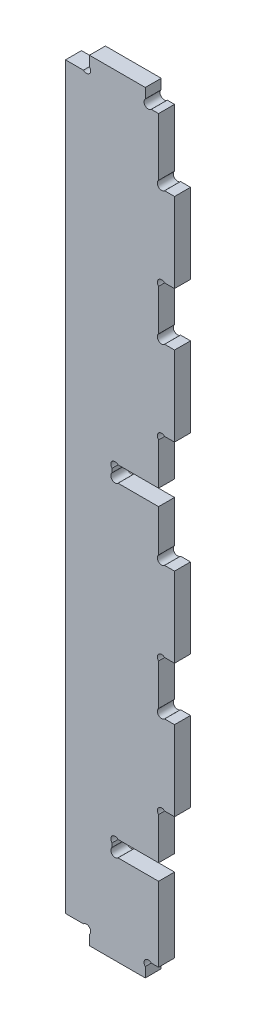
from build123d import *

# Parameters (mm, degrees)
EXTRUSION1_DEPTH        = 6
ESQUISSE2_R             = 1.1
ENL_V_MAT_EXTRU_1_DEPTH = 2


with BuildPart() as part:
    # Esquisse1 → Extrusion1 (new body)
    with BuildSketch(Plane.XY):
        with BuildLine():
            Line((0, 6), (6.7372583, 6))
            ThreePointArc((6.7372583, 6), (9, 6), (9, 3.7372583))
            Line((9, 3.7372583), (9, 0))
            Line((9, 0), (30, 0))
            Line((30, 0), (30, 3.7372583))
            ThreePointArc((30, 3.7372583), (30, 6), (32.2627417, 6))
            Line((32.2627417, 6), (35, 6))
            Line((35, 6), (35, 34))
            Line((35, 34), (19.7627417, 34))
            ThreePointArc((19.7627417, 34), (17.5, 34), (17.5, 36.2627417))
            Line((17.5, 36.2627417), (17.5, 37.7372583))
            ThreePointArc((17.5, 37.7372583), (17.5, 40), (19.7627417, 40))
            Line((19.7627417, 40), (35, 40))
            Line((35, 40), (35, 55.7372583))
            ThreePointArc((35, 55.7372583), (35, 58), (37.2627417, 58))
            Line((37.2627417, 58), (41, 58))
            Line((41, 58), (41, 88))
            Line((41, 88), (37.2627417, 88))
            ThreePointArc((37.2627417, 88), (35, 88), (35, 90.2627417))
            Line((35, 90.2627417), (35, 105.7372583))
            ThreePointArc((35, 105.7372583), (35, 108), (37.2627417, 108))
            Line((37.2627417, 108), (41, 108))
            Line((41, 108), (41, 138))
            Line((41, 138), (37.2627417, 138))
            ThreePointArc((37.2627417, 138), (35, 138), (35, 140.2627417))
            Line((35, 140.2627417), (35, 156))
            Line((35, 156), (19.7627417, 156))
            ThreePointArc((19.7627417, 156), (17.5, 156), (17.5, 158.2627417))
            Line((17.5, 158.2627417), (17.5, 159.7372583))
            ThreePointArc((17.5, 159.7372583), (17.5, 162), (19.7627417, 162))
            Line((19.7627417, 162), (35, 162))
            Line((35, 162), (35, 177.7372583))
            ThreePointArc((35, 177.7372583), (35, 180), (37.2627417, 180))
            Line((37.2627417, 180), (41, 180))
            Line((41, 180), (41, 210))
            Line((41, 210), (37.2627417, 210))
            ThreePointArc((37.2627417, 210), (35, 210), (35, 212.2627417))
            Line((35, 212.2627417), (35, 227.7372583))
            ThreePointArc((35, 227.7372583), (35, 230), (37.2627417, 230))
            Line((37.2627417, 230), (41, 230))
            Line((41, 230), (41, 260))
            Line((41, 260), (37.2627417, 260))
            ThreePointArc((37.2627417, 260), (35, 260), (35, 262.2627417))
            Line((35, 262.2627417), (35, 284))
            Line((35, 284), (32.2627417, 284))
            ThreePointArc((32.2627417, 284), (30, 284), (30, 286.2627417))
            Line((30, 286.2627417), (30, 290))
            Line((30, 290), (9, 290))
            Line((9, 290), (9, 286.2627417))
            ThreePointArc((9, 286.2627417), (9, 284), (6.7372583, 284))
            Line((6.7372583, 284), (0, 284))
            Line((0, 284), (0, 6))
        make_face()
    extrude(amount=EXTRUSION1_DEPTH)

    # Esquisse2 → Enlèv. mat.-Extru.1 (cut)
    with BuildSketch(Plane(origin=(0, 0, 0), x_dir=(-1, 0, 0), z_dir=(0, 0, -1))):
        with Locations((-4, 167)):
            Circle(ESQUISSE2_R)
        with Locations(Location((-26, 167, 0), (0, 0, 180))):  # turned: the seam where the file's is
            Circle(ESQUISSE2_R)
        with Locations((-26, 213)):
            Circle(ESQUISSE2_R)
        with Locations(Location((-4, 213, 0), (0, 0, 180))):  # turned: the seam where the file's is
            Circle(ESQUISSE2_R)
        with Locations(Location((-26, 223, 0), (0, 0, 180))):  # turned: the seam where the file's is
            Circle(ESQUISSE2_R)
        with Locations((-4, 223)):
            Circle(ESQUISSE2_R)
        with Locations((-26, 269)):
            Circle(ESQUISSE2_R)
        with Locations(Location((-4, 269, 0), (0, 0, 180))):  # turned: the seam where the file's is
            Circle(ESQUISSE2_R)
        with Locations((-4, 45)):
            Circle(ESQUISSE2_R)
        with Locations(Location((-26, 45, 0), (0, 0, 180))):  # turned: the seam where the file's is
            Circle(ESQUISSE2_R)
        with Locations((-26, 91)):
            Circle(ESQUISSE2_R)
        with Locations(Location((-4, 91, 0), (0, 0, 180))):  # turned: the seam where the file's is
            Circle(ESQUISSE2_R)
        with Locations(Location((-26, 101, 0), (0, 0, 180))):  # turned: the seam where the file's is
            Circle(ESQUISSE2_R)
        with Locations((-4, 101)):
            Circle(ESQUISSE2_R)
        with Locations((-26, 147)):
            Circle(ESQUISSE2_R)
        with Locations(Location((-4, 147, 0), (0, 0, 180))):  # turned: the seam where the file's is
            Circle(ESQUISSE2_R)
    extrude(amount=-ENL_V_MAT_EXTRU_1_DEPTH, mode=Mode.SUBTRACT)


solid = part.part
